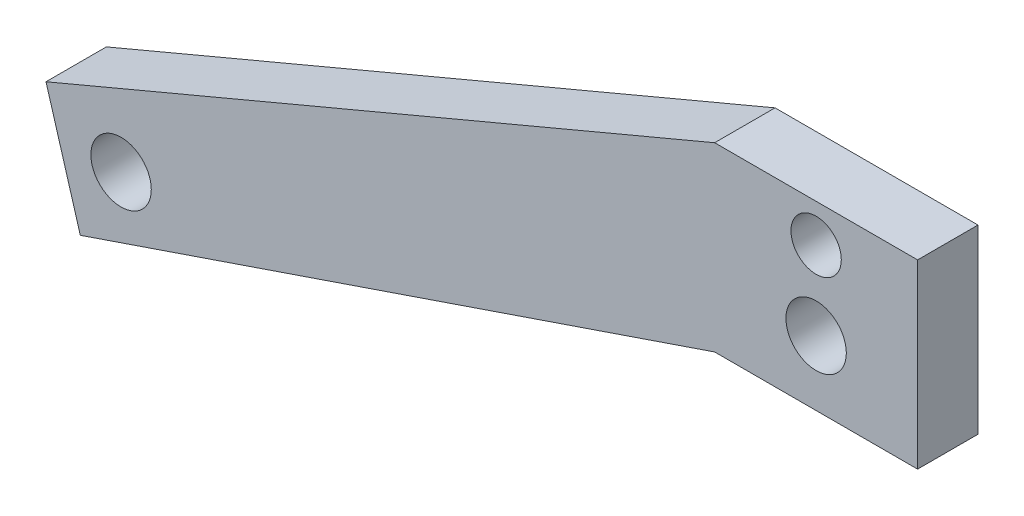
from build123d import *

# Parameters (mm, degrees)
SKETCH1_R           = 3.96875
SKETCH1_R_2         = 4.762500002
BOSS_EXTRUDE1_DEPTH = 9.525


with BuildPart() as part:
    # Sketch1 → Boss-Extrude1 (new body)
    with BuildSketch(Plane.XY):
        Polygon((-16.000014758, 44.999982542), (-121.431114587, 0.612137498), (-116.02062227, -17.653378451), (-16.000014758, 16.424982542), (15.999985242, 16.424982542), (15.999985242, 44.999982542), align=None)
        with Locations((-1.4758e-05, 38.999982542)):
            Circle(SKETCH1_R, mode=Mode.SUBTRACT)
        with Locations((-1.4758e-05, 26.647579582)):
            Circle(SKETCH1_R_2, mode=Mode.SUBTRACT)
        with Locations((-109.593110454, -5.815374318)):
            Circle(SKETCH1_R_2, mode=Mode.SUBTRACT)
    extrude(amount=BOSS_EXTRUDE1_DEPTH)


solid = part.part
